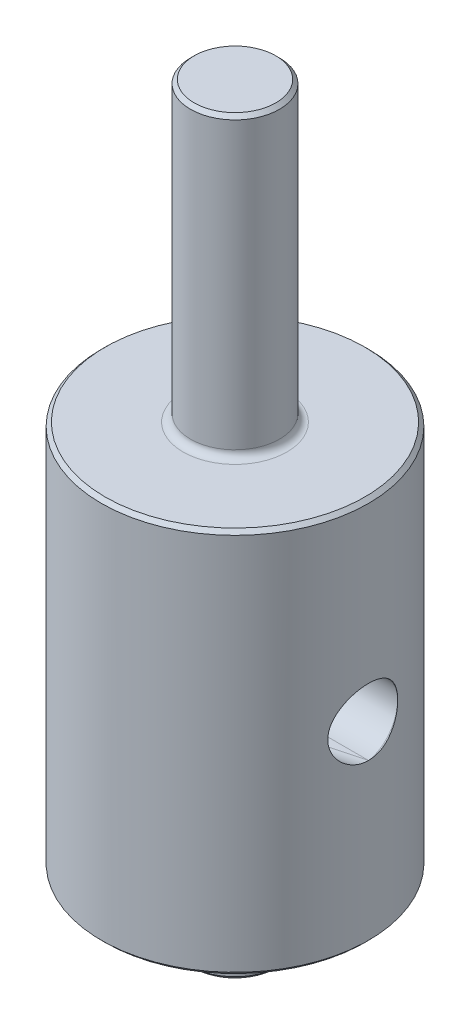
from build123d import *

# Parameters (mm, degrees)
ESBO_O2_R                  = 2.25
CORTE_EXTRUS_O2_DEPTH      = 19
ESBO_O7_R                  = 2.25
CORTE_EXTRUS_O6_DEPTH      = 3.329371528
CORTE_EXTRUS_O6_DEPTH_BACK = 20.716036402
CUT_EXTRUDE1_DEPTH         = 2.25
FILLET1_R                  = 0.5
CHAMFER1_SIZE              = 0.25
CHAMFER4_SIZE              = 0.25


with BuildPart() as part:
    # Esboço1 → Revolução1 (revolve)
    with BuildSketch(Plane.XY):
        Polygon((0, 33), (3, 33), (3, 13), (9, 13), (9, -13), (3, -13), (3, -17.5), (0, -17.5), (0, 0), align=None)
    revolve(axis=Axis((0, 0, 0), (0, 1, 0)))

    # Esboço2 → Corte-extrusão2 (cut, through all)
    with BuildSketch(Plane.ZY.offset(9)):
        Circle(ESBO_O2_R)
    extrude(amount=-CORTE_EXTRUS_O2_DEPTH, mode=Mode.SUBTRACT)

    # Esboço7 → Corte-extrusão6 (cut, two sides)
    with BuildSketch(Plane(origin=(-7.794228634, 0, 4.5), x_dir=(0.258819045, 0, 0.965925826), z_dir=(-0.965925826, 0, 0.258819045))) as corte_extrus_o6_sk:
        Circle(ESBO_O7_R)
    extrude(amount=CORTE_EXTRUS_O6_DEPTH, mode=Mode.SUBTRACT)
    extrude(corte_extrus_o6_sk.sketch, amount=-CORTE_EXTRUS_O6_DEPTH_BACK, mode=Mode.SUBTRACT)

    # Sketch1 → Cut-Extrude1 (cut, symmetric)
    with BuildSketch(Plane(origin=(0, 0, 0), x_dir=(1, 0, 0), z_dir=(0, 1, 0))):
        Polygon((9, 0), (-10.844388007, 0), (-10.42876147, -5.205920946), align=None)
    extrude(amount=CUT_EXTRUDE1_DEPTH, both=True, mode=Mode.SUBTRACT)

    # Fillet1
    fillet1_edges = [part.edges().sort_by_distance(p)[0] for p in [
        (-3, -13, 0),
        (-3, 13, 0),
    ]]
    fillet(fillet1_edges, radius=FILLET1_R)

    # Chamfer1
    chamfer1_edges = [part.edges().sort_by_distance(p)[0] for p in [
        (-3, -17.5, 0),
        (-3, 33, 0),
    ]]
    chamfer(chamfer1_edges, length=CHAMFER1_SIZE)

    # Chamfer4
    chamfer4_edges = [part.edges().sort_by_distance(p)[0] for p in [
        (-9, -13, 0),
        (-9, 13, 0),
    ]]
    chamfer(chamfer4_edges, length=CHAMFER4_SIZE)


solid = part.part
